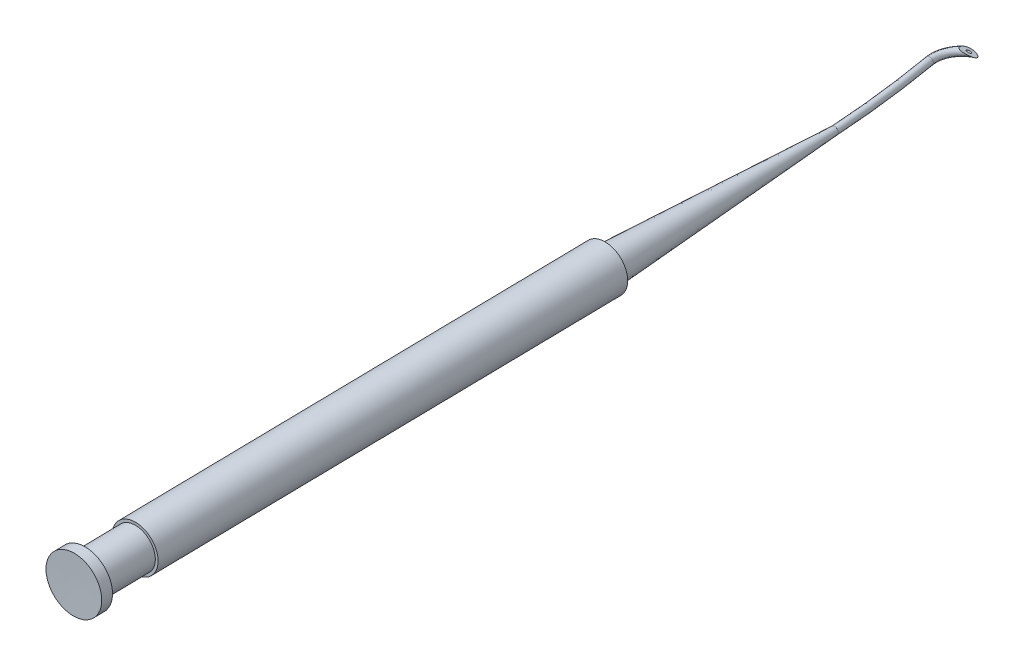
from build123d import *

# Parameters (mm, degrees)
SKETCH5_RX         = 0.499930018
SKETCH5_RY         = 0.499860046
SKETCH5_R          = 0.15
SKETCH7_W          = 3.67025273
SKETCH7_H          = 6.101354134
CUT_EXTRUDE1_DEPTH = 10


with BuildPart() as part:
    # Sketch2 → Revolve4 (revolve)
    with BuildSketch(Plane(origin=(0, 0, 0), x_dir=(1, 0, 0), z_dir=(0, 1, 0))):
        Polygon((24.886104147, 17.005765409), (26.107421074, -55.983659918), (29.857946011, -55.983659918), (29.832850335, -54.483869864), (28.807706852, -54.483869864), (28.690593697, -47.48484961), (29.065646191, -47.48484961), (27.972452613, 17.8475545), (27.163610623, 17.8475545), (24.837502632, 49.791775671), (24.337502632, 49.791775671), align=None)
    revolve(axis=Axis((24.886104147, 0, -17.005765409), (0.016730451, 0, 0.999860036)))


with BuildPart() as body_2:
    # Sweep1: sweep along a path in Sketch4
    with BuildLine(Plane(origin=(0, 0, 0), x_dir=(1, 0, 0), z_dir=(0, 1, 0))) as sweep1_path:
        ThreePointArc((24.337502632, 49.791775671), (23.66199483, 57.170782562), (22.582972321, 64.501659992))
        ThreePointArc((22.582972321, 64.501659992), (23.019193012, 67.040207811), (24.967268705, 68.725293748))
    # Sketch5 → Sweep1 (sweep)
    with BuildSketch(Plane(origin=(0, 5.85e-07, -49.791775671), x_dir=(-1, 0, 0), z_dir=(0, 1.2e-08, -1))):
        with Locations(Location((-24.337642586, -5.85e-07), (0, 0, -90.000040234))):
            Ellipse(SKETCH5_RX, SKETCH5_RY)
        with Locations((-24.337642586, -5.85e-07)):
            Circle(SKETCH5_R, mode=Mode.SUBTRACT)
    sweep(path=sweep1_path.line)

    # Sketch7 → Cut-Extrude1 (cut)
    with BuildSketch(Plane(origin=(10.399402161, 18.887006453, -3.28005675), x_dir=(0.300800703, 4e-09, 0.953687022), z_dir=(-0.47684351, -0.866025404, 0.150400355))):
        with Locations((-56.91922837, -37.333448457)):
            Rectangle(SKETCH7_W, SKETCH7_H)
    extrude(amount=-CUT_EXTRUDE1_DEPTH, mode=Mode.SUBTRACT)


solid = Compound([part.part, body_2.part])
